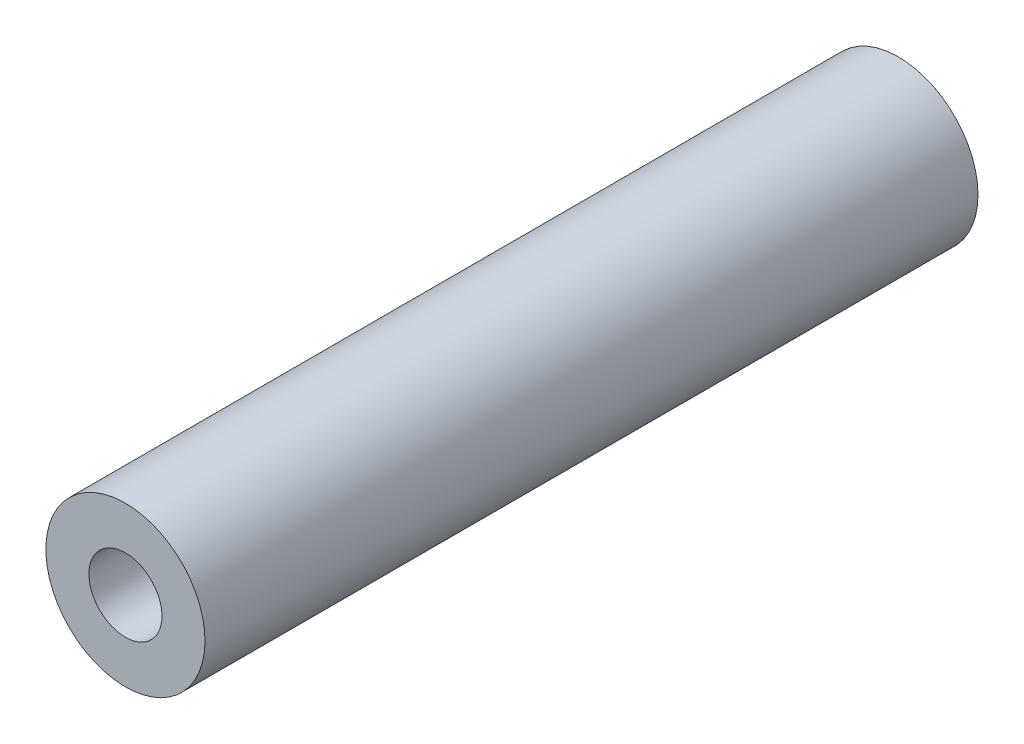
from build123d import *

# Parameters (mm, degrees)
SKETCH1_R           = 5.55625
SKETCH1_R_2         = 2.5527
BOSS_EXTRUDE1_DEPTH = 53.975


with BuildPart() as part:
    # Sketch1 → Boss-Extrude1 (new body)
    with BuildSketch(Plane.XY):
        Circle(SKETCH1_R)
        Circle(SKETCH1_R_2, mode=Mode.SUBTRACT)
    extrude(amount=BOSS_EXTRUDE1_DEPTH)


solid = part.part
